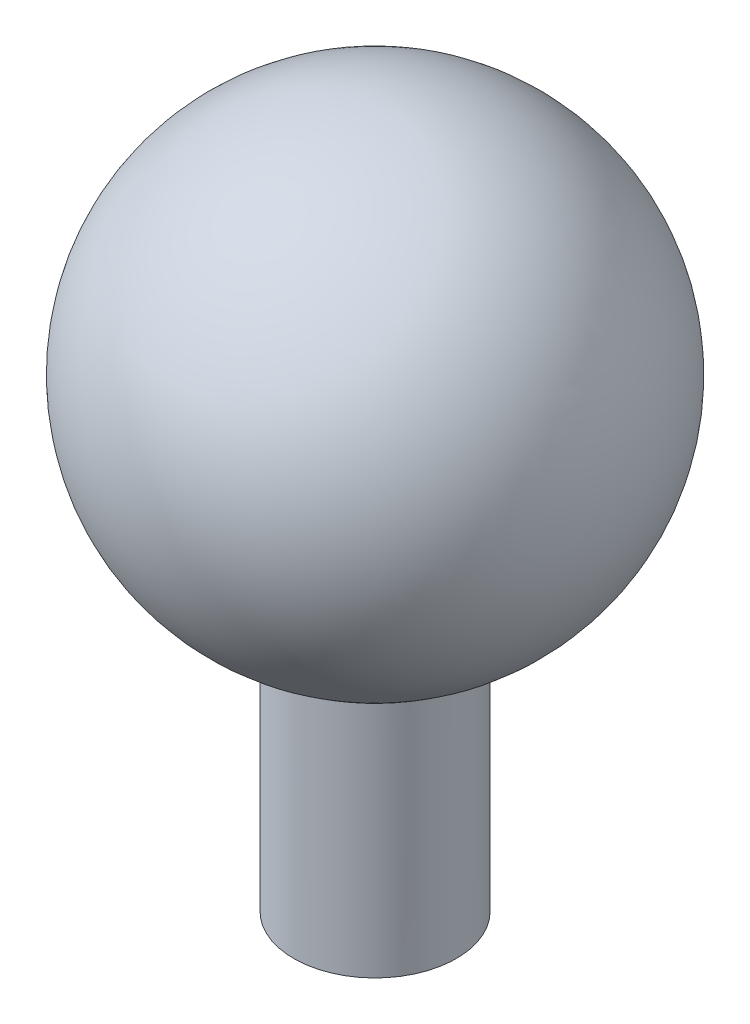
from build123d import *


with BuildPart() as part:
    # Sketch1 → Revolve1 (revolve)
    with BuildSketch(Plane.XY):
        with BuildLine():
            Line((0, 5), (0, -10))
            Line((0, -10), (-1.75, -10))
            Line((-1.75, -10), (-1.75, -4.683748499))
            ThreePointArc((-1.75, -4.683748499), (-4.920301947, 0.889173073), (0, 5))
        make_face()
    revolve(axis=Axis((0, 5, 0), (0, -1, 0)))


solid = part.part
